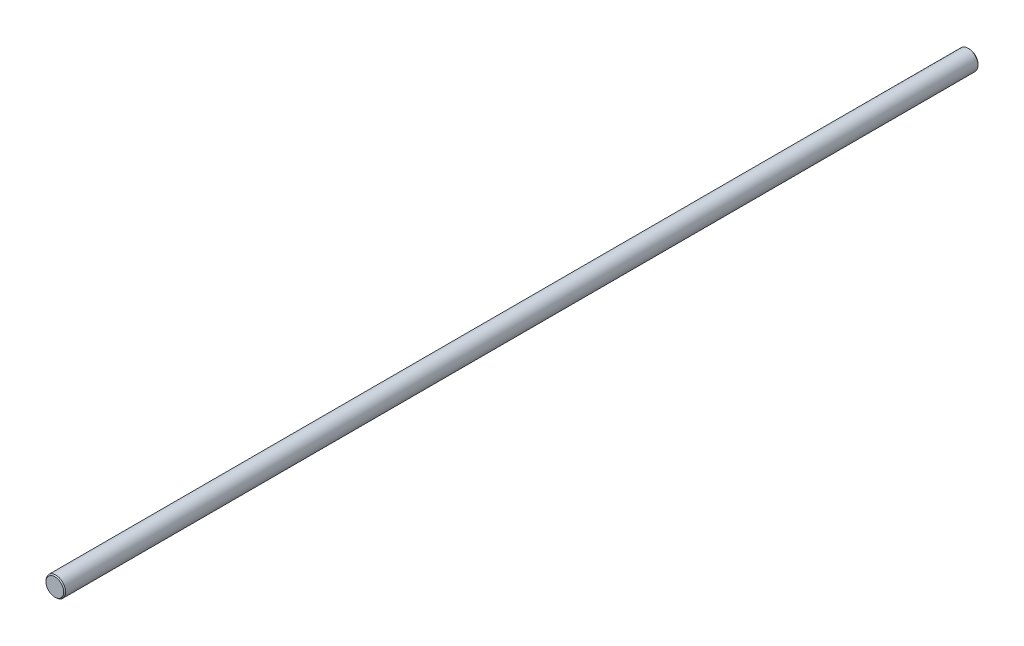
from build123d import *

# Parameters (mm, degrees)
SKETCH1_R           = 5
BOSS_EXTRUDE1_DEPTH = 465
CHAMFER1_SIZE       = 0.5
CHAMFER2_SIZE       = 0.5


with BuildPart() as part:
    # Sketch1 → Boss-Extrude1 (new body)
    with BuildSketch(Plane.XY):
        Circle(SKETCH1_R)
    extrude(amount=BOSS_EXTRUDE1_DEPTH)

    # Chamfer1
    chamfer1_edges = [part.edges().sort_by_distance(p)[0] for p in [
        (-5, 0, 465),
    ]]
    chamfer(chamfer1_edges, length=CHAMFER1_SIZE)

    # Chamfer2
    chamfer2_edges = [part.edges().sort_by_distance(p)[0] for p in [
        (-5, 0, 0),
    ]]
    chamfer(chamfer2_edges, length=CHAMFER2_SIZE)


solid = part.part
